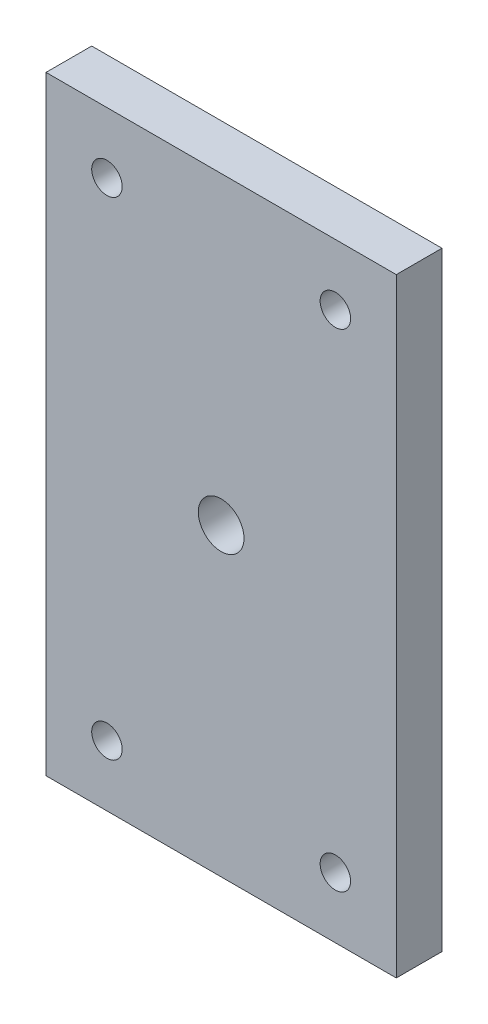
from build123d import *

# Parameters (mm, degrees)
SKETCH1_W           = 23
SKETCH1_H           = 40
BOSS_EXTRUDE1_DEPTH = 3
SKETCH2_R           = 1.5
CUT_EXTRUDE1_DEPTH  = 4
CUT_EXTRUDE4_DEPTH  = 5
SKETCH4_R           = 1
CUT_EXTRUDE5_DEPTH  = 4


with BuildPart() as part:
    # Sketch1 → Boss-Extrude1 (new body)
    with BuildSketch(Plane.XY):
        with Locations((11.5, 20)):
            Rectangle(SKETCH1_W, SKETCH1_H)
    extrude(amount=BOSS_EXTRUDE1_DEPTH)

    # Sketch2 → Cut-Extrude1 (cut, through all)
    with BuildSketch(Plane.XY.offset(3)):
        with Locations((11.5, 20)):
            Circle(SKETCH2_R)
    extrude(amount=-CUT_EXTRUDE1_DEPTH, mode=Mode.SUBTRACT)

    # Sketch3 → Cut-Extrude4 (cut, symmetric)
    with BuildSketch(Plane(origin=(11.5, 0, 0), x_dir=(0, 0, -1), z_dir=(1, 0, 0))):
        with BuildLine():
            Line((0, 13.697030082), (0, 12.302969918))
            ThreePointArc((0, 12.302969918), (-0.029066134, 12.391711115), (-0.105, 12.446060799))
            ThreePointArc((-0.105, 12.446060799), (-0.175126488, 12.471018632), (-0.243202247, 12.501123596))
            ThreePointArc((-0.243202247, 12.501123596), (-0.555, 13), (-0.243202247, 13.498876404))
            ThreePointArc((-0.243202247, 13.498876404), (-0.175126488, 13.528981368), (-0.105, 13.553939201))
            ThreePointArc((-0.105, 13.553939201), (-0.029066134, 13.608288885), (0, 13.697030082))
        make_face()
        with BuildLine():
            Line((0, 11.697030082), (0, 10.302969918))
            ThreePointArc((0, 10.302969918), (-0.029066134, 10.391711115), (-0.105, 10.446060799))
            ThreePointArc((-0.105, 10.446060799), (-0.175126488, 10.471018632), (-0.243202247, 10.501123596))
            ThreePointArc((-0.243202247, 10.501123596), (-0.555, 11), (-0.243202247, 11.498876404))
            ThreePointArc((-0.243202247, 11.498876404), (-0.175126488, 11.528981368), (-0.105, 11.553939201))
            ThreePointArc((-0.105, 11.553939201), (-0.029066134, 11.608288885), (0, 11.697030082))
        make_face()
        with BuildLine():
            Line((0, 9.697030082), (0, 8.302969918))
            ThreePointArc((0, 8.302969918), (-0.029066134, 8.391711115), (-0.105, 8.446060799))
            ThreePointArc((-0.105, 8.446060799), (-0.175126488, 8.471018632), (-0.243202247, 8.501123596))
            ThreePointArc((-0.243202247, 8.501123596), (-0.555, 9), (-0.243202247, 9.498876404))
            ThreePointArc((-0.243202247, 9.498876404), (-0.175126488, 9.528981368), (-0.105, 9.553939201))
            ThreePointArc((-0.105, 9.553939201), (-0.029066134, 9.608288885), (0, 9.697030082))
        make_face()
        with BuildLine():
            Line((0, 7.697030082), (0, 6.302969918))
            ThreePointArc((0, 6.302969918), (-0.029066134, 6.391711115), (-0.105, 6.446060799))
            ThreePointArc((-0.105, 6.446060799), (-0.175126488, 6.471018632), (-0.243202247, 6.501123596))
            ThreePointArc((-0.243202247, 6.501123596), (-0.555, 7), (-0.243202247, 7.498876404))
            ThreePointArc((-0.243202247, 7.498876404), (-0.175126488, 7.528981368), (-0.105, 7.553939201))
            ThreePointArc((-0.105, 7.553939201), (-0.029066134, 7.608288885), (0, 7.697030082))
        make_face()
        with BuildLine():
            Line((0, 5.697030082), (0, 4.302969918))
            ThreePointArc((0, 4.302969918), (-0.029066134, 4.391711115), (-0.105, 4.446060799))
            ThreePointArc((-0.105, 4.446060799), (-0.175126488, 4.471018632), (-0.243202247, 4.501123596))
            ThreePointArc((-0.243202247, 4.501123596), (-0.555, 5), (-0.243202247, 5.498876404))
            ThreePointArc((-0.243202247, 5.498876404), (-0.175126488, 5.528981368), (-0.105, 5.553939201))
            ThreePointArc((-0.105, 5.553939201), (-0.029066134, 5.608288885), (0, 5.697030082))
        make_face()
        with BuildLine():
            Line((0, 3.697030082), (0, 2.302969918))
            ThreePointArc((0, 2.302969918), (-0.029066134, 2.391711115), (-0.105, 2.446060799))
            ThreePointArc((-0.105, 2.446060799), (-0.175126488, 2.471018632), (-0.243202247, 2.501123596))
            ThreePointArc((-0.243202247, 2.501123596), (-0.555, 3), (-0.243202247, 3.498876404))
            ThreePointArc((-0.243202247, 3.498876404), (-0.175126488, 3.528981368), (-0.105, 3.553939201))
            ThreePointArc((-0.105, 3.553939201), (-0.029066134, 3.608288885), (0, 3.697030082))
        make_face()
        with BuildLine():
            Line((0, 1.697030082), (0, 0.302969918))
            ThreePointArc((0, 0.302969918), (-0.029066134, 0.391711115), (-0.105, 0.446060799))
            ThreePointArc((-0.105, 0.446060799), (-0.175126488, 0.471018632), (-0.243202247, 0.501123596))
            ThreePointArc((-0.243202247, 0.501123596), (-0.555, 1), (-0.243202247, 1.498876404))
            ThreePointArc((-0.243202247, 1.498876404), (-0.175126488, 1.528981368), (-0.105, 1.553939201))
            ThreePointArc((-0.105, 1.553939201), (-0.029066134, 1.608288885), (0, 1.697030082))
        make_face()
    cut_extrude4 = extrude(amount=CUT_EXTRUDE4_DEPTH, both=True, mode=Mode.SUBTRACT)

    # Mirror1: Cut-Extrude4 across plane
    add(cut_extrude4.mirror(Plane(origin=(0, 20, 0), x_dir=(0, 0, 1), z_dir=(0, -1, 0))), mode=Mode.SUBTRACT)

    # Sketch4 → Cut-Extrude5 (cut, through all)
    with BuildSketch(Plane(origin=(0, 0, 0), x_dir=(-1, 0, 0), z_dir=(0, 0, -1))):
        with Locations((-19, 36)):
            Circle(SKETCH4_R)
        with Locations((-19, 4)):
            Circle(SKETCH4_R)
        with Locations((-4, 4)):
            Circle(SKETCH4_R)
        with Locations((-4, 36)):
            Circle(SKETCH4_R)
    extrude(amount=-CUT_EXTRUDE5_DEPTH, mode=Mode.SUBTRACT)


solid = part.part
